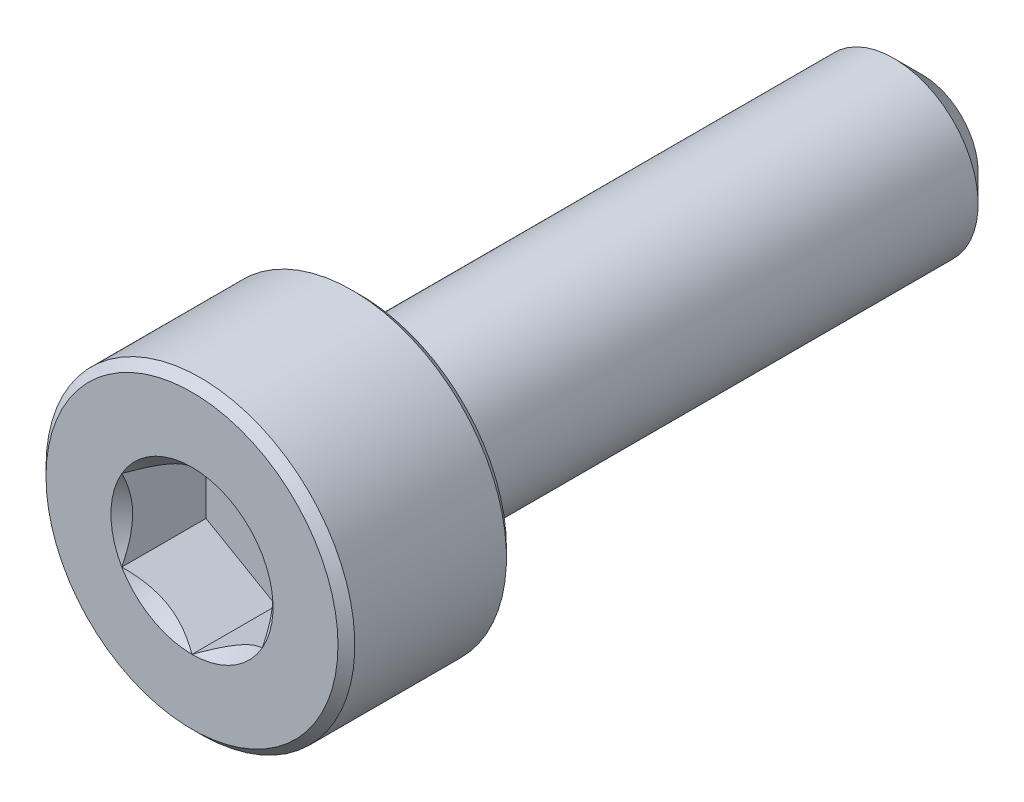
from build123d import *

# Parameters (mm, degrees)
CUT_EXTRUDE1_START = -1.5
CUT_EXTRUDE1_DEPTH = 1.5
SKETCH4_R          = 1.443375673
CUT_EXTRUDE2_DEPTH = 0.5
CUT_EXTRUDE2_TAPER = 45


with BuildPart() as part:
    # Sketch2 → Revolve1 (revolve)
    with BuildSketch(Plane(origin=(0, 0, 0), x_dir=(0, 0, -1), z_dir=(1, 0, 0))):
        Polygon((-6.35, 2.75), (-3.65, 2.75), (-3.5, 2.6), (-3.5, 1.5), (6, 1.5), (6.5, 1), (6.5, 0), (-6.5, 0), (-6.5, 2.6), align=None)
    revolve(axis=Axis((0, 0, -6.5), (0, 0, 1)))

    # Sketch3 → Cut-Extrude1 (cut)
    with BuildSketch(Plane.XY.offset(6.5).offset(CUT_EXTRUDE1_START)):
        Polygon((0, 1.443375673), (-1.25, 0.721687836), (-1.25, -0.721687836), (0, -1.443375673), (1.25, -0.721687836), (1.25, 0.721687836), align=None)
    extrude(amount=CUT_EXTRUDE1_DEPTH, mode=Mode.SUBTRACT)

    # Sketch4 → Cut-Extrude2 (cut)
    with BuildSketch(Plane.XY.offset(6.5)):
        Circle(SKETCH4_R)
    extrude(amount=-CUT_EXTRUDE2_DEPTH, taper=CUT_EXTRUDE2_TAPER, mode=Mode.SUBTRACT)


solid = part.part
